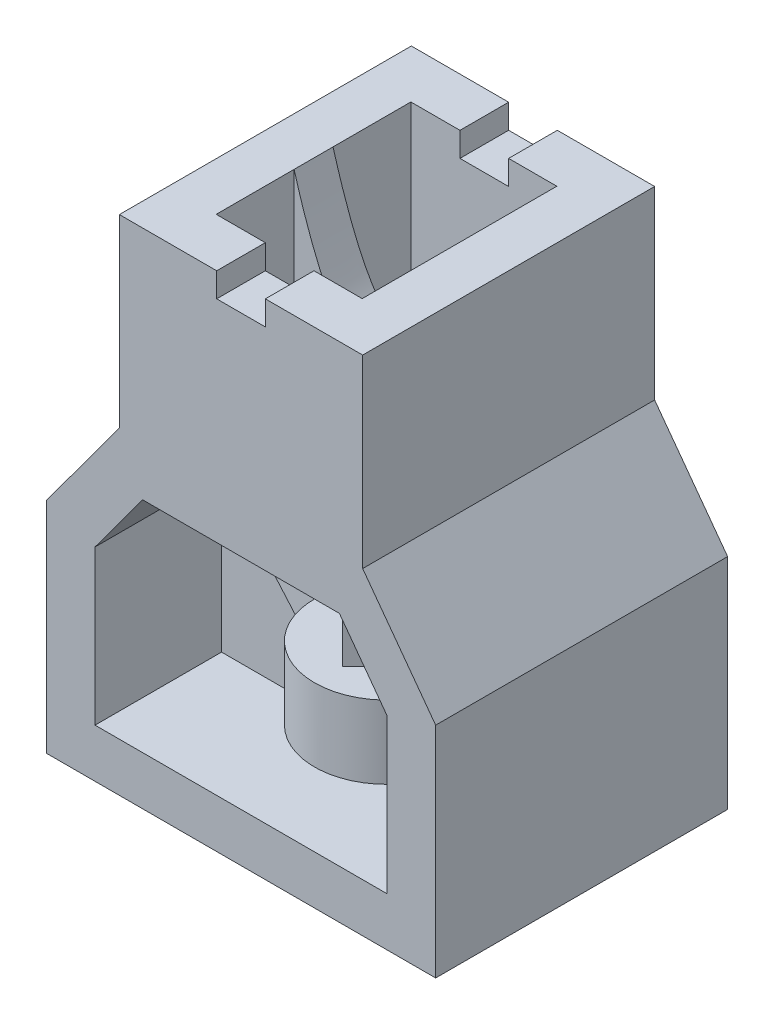
from build123d import *

# Parameters (mm, degrees)
EXTRUDE_1_DEPTH          = 30
EXTRUDE_1_DEPTH_BACK     = 30
SKETCH_2_W               = 30
SKETCH_2_H               = 40
CUT_EXTRUDE_1_DEPTH      = 32
SKETCH_3_W               = 10
SKETCH_3_H               = 10
CUT_EXTRUDE_2_DEPTH      = 144.824858479
SKETCH_4_R               = 14.906957443
EXTRUDE_2_DEPTH          = 15
CUT_EXTRUDE_3_DEPTH      = 37
CUT_EXTRUDE_3_DEPTH_BACK = 116.939784206
EXTRUDE_3_DEPTH          = 4
EXTRUDE_3_DEPTH_BACK     = 4
EXTRUDE_4_DEPTH          = 4
EXTRUDE_4_DEPTH_BACK     = 4


with BuildPart() as part:
    # Эскиз1 → Бобышка-Вытянуть1 (new, two sides: drawn at the far end of the back side and taken through both)
    with BuildSketch(Plane.XY.offset(-EXTRUDE_1_DEPTH_BACK)):
        Polygon((0, 0), (80, 0), (80, 45), (65, 65.371127092), (65, 103.371127092), (40, 103.371127092), (15, 103.371127092), (15, 65.371127092), (0, 45), align=None)
        Polygon((10, 10), (70, 10), (70, 41.715496922), (60.218138384, 55), (19.781861616, 55), (10, 41.715496922), align=None, mode=Mode.SUBTRACT)
    extrude(amount=EXTRUDE_1_DEPTH + EXTRUDE_1_DEPTH_BACK)

    # Эскиз2 → Вырез-Вытянуть1 (cut)
    with BuildSketch(Plane(origin=(0, 103.371127092, 0), x_dir=(1, 0, 0), z_dir=(0, 1, 0))):
        with Locations((39.906957443, -0.006497208)):
            Rectangle(SKETCH_2_W, SKETCH_2_H)
    extrude(amount=-CUT_EXTRUDE_1_DEPTH, mode=Mode.SUBTRACT)

    # Эскиз3 → Вырез-Вытянуть2 (cut, through all)
    with BuildSketch(Plane.XY.offset(30)):
        with Locations((40, 103.371127092)):
            Rectangle(SKETCH_3_W, SKETCH_3_H)
    extrude(amount=-CUT_EXTRUDE_2_DEPTH, mode=Mode.SUBTRACT)

    # Эскиз4 → Бобышка-Вытянуть2 (add)
    with BuildSketch(Plane(origin=(0, 10, 0), x_dir=(1, 0, 0), z_dir=(0, 1, 0))):
        with Locations((40, 0)):
            Circle(SKETCH_4_R)
    extrude(amount=EXTRUDE_2_DEPTH)

    # Эскиз5 → Вырез-Вытянуть3 (cut, two sides: drawn at the far end of the back side and taken through both)
    with BuildSketch(Plane(origin=(0, 25, 0), x_dir=(1, 0, 0), z_dir=(0, 1, 0)).offset(-CUT_EXTRUDE_3_DEPTH_BACK)):
        Polygon((40, 9.192388155), (30.807611845, 0), (40, -9.192388155), (49.192388155, 0), align=None)
    extrude(amount=CUT_EXTRUDE_3_DEPTH + CUT_EXTRUDE_3_DEPTH_BACK, mode=Mode.SUBTRACT)

    # Эскиз6 → Бобышка-Вытянуть3 (add, two sides: drawn at the far end of the back side and taken through both)
    with BuildSketch(Plane.XY.offset(-EXTRUDE_3_DEPTH_BACK)):
        Polygon((70, 10), (51.541791272, 10), (51.541791272, 20.404686065), (70, 41.715496922), align=None)
        Polygon((10, 10), (10, 41.715496922), (28.458208728, 20.404686065), (28.458208728, 10), align=None)
    extrude(amount=EXTRUDE_3_DEPTH + EXTRUDE_3_DEPTH_BACK)

    # Эскиз8 → Бобышка-Вытянуть4 (add, two sides: drawn at the far end of the back side and taken through both)
    with BuildSketch(Plane.XY.offset(-EXTRUDE_4_DEPTH_BACK)):
        with BuildLine():
            Line((54.906957443, 103.371127092), (54.906957443, 77.371127092))
            Line((54.906957443, 77.371127092), (54.906957443, 71.371127092))
            Line((54.906957443, 71.371127092), (24.906957443, 71.371127092))
            Line((24.906957443, 71.371127092), (24.906957443, 77.371127092))
            Line((24.906957443, 77.371127092), (24.906957443, 103.371127092))
            add(Edge.make_bspline(
                [(24.906957443, 103.371127092), (39.906957443, 51.371127092), (54.906957443, 103.371127092)],
                knots=[0, 0, 0, 1, 1, 1], degree=2))
        make_face()
    extrude(amount=EXTRUDE_4_DEPTH + EXTRUDE_4_DEPTH_BACK)


solid = part.part
